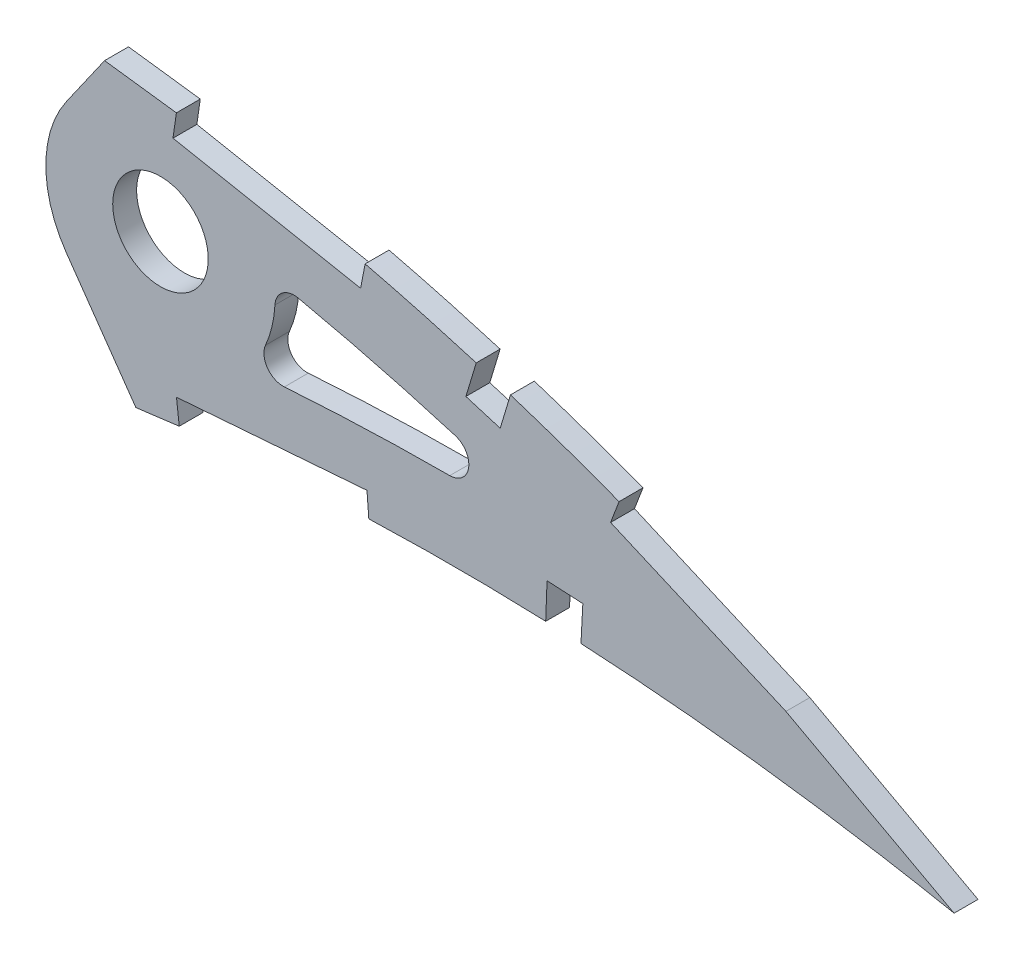
from build123d import *

# Parameters (mm, degrees)
BOSS_EXTRUDE1_DEPTH = 3.175
SKETCH3_R           = 6.35
CUT_EXTRUDE2_DEPTH  = 7.62
CUT_EXTRUDE3_DEPTH  = 4.1750001
CUT_EXTRUDE4_DEPTH  = 4.1750001
FILLET1_R           = 2.54


with BuildPart() as part:
    # Sketch1 → Boss-Extrude1 (new body)
    with BuildSketch(Plane.XY):
        with BuildLine():
            Line((383.459719795, -0.598570683), (387.151098381, -1.385981683))
            Line((387.151098381, -1.385981683), (383.938576586, 0.598570683))
            add(Edge.make_bspline(
                [(383.938576586, 0.598570683), (383.909164402, 0.616740215), (383.791629853, 0.689347806), (383.526803342, 0.851788775), (383.085812234, 1.122342517), (382.46846306, 1.499129399), (381.675235414, 1.981149322), (380.705730092, 2.565026812), (379.560552258, 3.248864764), (378.239979352, 4.02942936), (376.744146546, 4.903065392), (375.073623444, 5.866233811), (373.228555337, 6.913481558), (371.209656947, 8.040529653), (369.017620878, 9.242017712), (366.652862008, 10.5125194), (364.116227136, 11.845572217), (361.408689747, 13.235442203), (358.530743662, 14.674454529), (355.483745734, 16.156620323), (352.268711027, 17.674549225), (348.886737002, 19.220143157), (345.339766501, 20.787101279), (341.62878015, 22.365681942), (337.755892849, 23.949045726), (333.722753433, 25.528181676), (329.531749722, 27.095897536), (325.184498663, 28.642037582), (320.684250026, 30.159844956), (316.03318694, 31.639459621), (311.234635387, 33.072845765), (306.291383411, 34.45071), (301.207551835, 35.76598594), (295.986364862, 37.009095199), (290.632247735, 38.171716814), (285.149456354, 39.246851106), (279.542589067, 40.223764407), (273.827182957, 41.101695037), (268.095197614, 41.831984573), (262.375005403, 42.548231339), (256.663331957, 43.221079634), (250.881849899, 43.865424929), (245.036121341, 44.477639467), (239.131944816, 45.055808842), (233.175297421, 45.597437688), (227.172369204, 46.100937725), (221.12896887, 46.563455864), (215.051468851, 46.984279591), (208.945877574, 47.359709224), (202.818698224, 47.689463037), (196.676150699, 47.971241104), (190.524627328, 48.20310193), (184.370660154, 48.383645908), (178.220637202, 48.511143259), (172.081217377, 48.584792389), (165.95878665, 48.602580967), (159.860000816, 48.564190717), (153.791246295, 48.468303513), (147.759185686, 48.313606629), (141.770214134, 48.099811437), (135.830807778, 47.827010592), (129.947469668, 47.492919603), (124.126582163, 47.099667535), (118.374627308, 46.64560247), (112.697924861, 46.1306036), (107.102424066, 45.556817635), (101.594354639, 44.922683996), (96.179619551, 44.23000695), (90.864141437, 43.480144639), (85.653884398, 42.672688505), (80.554429795, 41.809970933), (75.571281385, 40.892874577), (70.709711341, 39.924088059), (65.975012599, 38.903864189), (61.372197101, 37.835263284), (56.906048373, 36.72014713), (52.581367423, 35.560557176), (48.402538226, 34.359275924), (44.373786491, 33.11902871), (40.499808771, 31.84117832), (36.783532955, 30.530569775), (33.229524089, 29.188133497), (29.840504666, 27.818005118), (26.620446377, 26.422055375), (23.571754691, 25.004539962), (20.697880073, 23.567072571), (18.000870717, 22.113680535), (15.483434196, 20.646592482), (13.147993867, 19.168533315), (10.995531238, 17.683252327), (9.029014018, 16.191681681), (7.249117676, 14.697590602), (5.656968684, 13.203254087), (4.254842735, 11.709701653), (3.042689485, 10.219563342), (2.022097407, 8.734019375), (1.193243635, 7.254475378), (0.55800286, 5.78200614), (0.115745172, 4.317439731), (-0.126343705, 2.862937809), (-0.186601112, 1.417334332), (-0.062107432, 0.471738862), (0, 0)],
                knots=[0, 0, 0, 0, 0.00025409, 0.001015374, 0.002283359, 0.004056577, 0.006330982, 0.009105274, 0.01237449, 0.016134024, 0.020379661, 0.025105976, 0.030306237, 0.035972206, 0.042099523, 0.048678064, 0.055701664, 0.063160184, 0.071045824, 0.079349827, 0.08806291, 0.097175757, 0.106678112, 0.116561573, 0.126814276, 0.1374283, 0.148393618, 0.15969976, 0.171338126, 0.183297699, 0.195569604, 0.208143556, 0.221011594, 0.234161831, 0.247587451, 0.261276823, 0.27522271, 0.289414144, 0.3037712, 0.317689227, 0.331784111, 0.346039677, 0.36044387, 0.374982721, 0.389640455, 0.404403317, 0.419256601, 0.43418675, 0.449177265, 0.464214782, 0.479284009, 0.49436974, 0.509457833, 0.524532346, 0.53957932, 0.554582984, 0.569529546, 0.584403417, 0.599190992, 0.613876838, 0.628447475, 0.642888675, 0.657186054, 0.671325546, 0.685294014, 0.699078148, 0.712665095, 0.726042645, 0.739197713, 0.752117587, 0.764792042, 0.777208152, 0.789355685, 0.80122396, 0.812803686, 0.824082909, 0.835054602, 0.845709571, 0.856037853, 0.866033835, 0.875688843, 0.884997719, 0.893953426, 0.902552897, 0.910789386, 0.918660734, 0.926166253, 0.933302626, 0.94007122, 0.94647478, 0.952517526, 0.958204819, 0.963546652, 0.9685566, 0.973249913, 0.977651041, 0.981787043, 0.985694226, 0.989415109, 0.993001157, 0.996508416, 1, 1, 1, 1], degree=3))
            add(Edge.make_bspline(
                [(0, 0), (0.098594067, -0.465429756), (0.296235321, -1.398428295), (0.833200827, -2.741559621), (1.543312041, -4.032697891), (2.441472641, -5.268413507), (3.521710628, -6.448368806), (4.781640288, -7.573790979), (6.220025893, -8.64407503), (7.834984953, -9.658733762), (9.624171422, -10.618844355), (11.585574313, -11.523809795), (13.717405168, -12.373347376), (16.017341357, -13.166321391), (18.482571114, -13.903939589), (21.110750633, -14.584404413), (23.898891402, -15.208666937), (26.844311765, -15.775133676), (29.943802121, -16.284380139), (33.194142548, -16.736121271), (36.59199678, -17.130639725), (40.134031288, -17.46710754), (43.816742631, -17.74624851), (47.636460203, -17.96824782), (51.589476278, -18.133809384), (55.672004278, -18.242303834), (59.880045838, -18.295422597), (64.209798061, -18.293963098), (68.657025429, -18.237535039), (73.217928944, -18.129255696), (77.888131918, -17.96843911), (82.663418096, -17.757031491), (87.53948011, -17.497160264), (92.511944666, -17.189706447), (97.576435823, -16.836032634), (102.728556211, -16.438975174), (107.9636256, -15.999524359), (113.277078315, -15.52024171), (118.664210326, -15.003526584), (124.120367239, -14.4510143), (129.640733027, -13.865303885), (135.220390799, -13.248293384), (140.854593983, -12.603274503), (146.538195749, -11.931414237), (152.266389991, -11.236548635), (158.033787934, -10.52000534), (163.835566864, -9.784544171), (169.666508639, -9.033628137), (175.521154495, -8.267171513), (181.394580274, -7.490635069), (187.28112183, -6.703379195), (193.175655329, -5.90945278), (199.072724256, -5.111323575), (204.966584816, -4.309237241), (210.852056119, -3.506517822), (216.72367834, -2.705368887), (222.575700149, -1.905863728), (228.402826975, -1.111976133), (234.199191111, -0.323609112), (239.959447702, 0.457639018), (245.678076832, 1.229436212), (251.34968319, 1.990808513), (256.968416226, 2.741274105), (262.528623029, 3.481114832), (267.941468501, 4.187874758), (273.192808754, 4.89918891), (278.300339848, 5.482308989), (283.344275668, 5.980022849), (288.329855672, 6.388079628), (293.25109327, 6.712349854), (298.102349784, 6.95515067), (302.877843519, 7.119871856), (307.571542288, 7.211400107), (312.17758361, 7.232058132), (316.689680406, 7.188433969), (321.101964205, 7.084044048), (325.408277014, 6.923573954), (329.602611012, 6.712437706), (333.679008651, 6.45639092), (337.631349997, 6.159210609), (341.4541277, 5.827834534), (345.141443703, 5.46711367), (348.687636023, 5.081169316), (352.087530269, 4.678088588), (355.335684636, 4.260525247), (358.42721331, 3.835341496), (361.357139876, 3.406846029), (364.120823945, 2.98050952), (366.713923524, 2.560399127), (369.132249836, 2.152090859), (371.372014685, 1.759399564), (373.429331453, 1.386160167), (375.301346074, 1.037081953), (376.984361404, 0.713898906), (378.476126466, 0.421937235), (379.773867448, 0.162485176), (380.875681878, -0.060801967), (381.779645661, -0.247042835), (382.484385883, -0.393180216), (382.98851051, -0.499447588), (383.291474212, -0.56268208), (383.426084821, -0.591395979), (383.459719795, -0.598570683)],
                knots=[0, 0, 0, 0, 0.003638255, 0.007293231, 0.011028136, 0.014901081, 0.018963272, 0.023258475, 0.027820626, 0.032679082, 0.03785316, 0.043361875, 0.049214679, 0.055422346, 0.061988786, 0.068918036, 0.076211157, 0.083868392, 0.091887411, 0.100265912, 0.108999867, 0.11808453, 0.127514843, 0.13728527, 0.147387918, 0.157816481, 0.168563473, 0.179619128, 0.190977373, 0.202626974, 0.214560478, 0.226767249, 0.239236417, 0.251959004, 0.264923895, 0.278119703, 0.291536035, 0.30516028, 0.318980685, 0.332985499, 0.347162791, 0.361498603, 0.375980747, 0.390597192, 0.405332594, 0.420174823, 0.435109533, 0.450124276, 0.465203068, 0.480333154, 0.495500583, 0.510689775, 0.525887335, 0.541078314, 0.556247233, 0.571381785, 0.586466041, 0.601484516, 0.616424329, 0.631269423, 0.646006524, 0.660620684, 0.675098187, 0.689422858, 0.703581825, 0.716907564, 0.730009274, 0.742952128, 0.755725558, 0.768319952, 0.780724338, 0.792926529, 0.804916041, 0.816679084, 0.828203524, 0.839474901, 0.850481359, 0.861207697, 0.871639326, 0.881763414, 0.891563605, 0.901027365, 0.910138977, 0.918883977, 0.927249278, 0.935221104, 0.942784739, 0.949928188, 0.956638465, 0.962904204, 0.968712288, 0.974054485, 0.978918432, 0.983297218, 0.987180246, 0.990560675, 0.993433358, 0.995790626, 0.997629588, 0.998945816, 0.999736593, 1, 1, 1, 1], degree=3))
        make_face()
    extrude(amount=BOSS_EXTRUDE1_DEPTH)

    # Sketch3 → Cut-Extrude2 (cut)
    with BuildSketch(Plane(origin=(0, 0, 0), x_dir=(-1, 0, 0), z_dir=(0, 0, -1))):
        with Locations((-272.41988512, 26.255421435)):
            Circle(SKETCH3_R)
    extrude(amount=-CUT_EXTRUDE2_DEPTH, mode=Mode.SUBTRACT)

    # Sketch4 → Cut-Extrude3 (cut, through all)
    with BuildSketch(Plane.XY.offset(3.175)):
        with BuildLine():
            ThreePointArc((258.636275142, 32.756936333), (259.238482127, 33.904487726), (259.936007965, 34.996726325))
            Line((259.936007965, 34.996726325), (264.993177896, 42.219113481))
            add(Edge.make_bspline(
                [(264.993177896, 42.219113481), (264.128267545, 42.326681207), (261.359885786, 42.667814769), (256.663331957, 43.221079634), (250.881849899, 43.865424929), (245.036121341, 44.477639467), (239.131944816, 45.055808842), (233.175297421, 45.597437688), (227.172369204, 46.100937725), (221.12896887, 46.563455864), (215.051468851, 46.984279591), (208.945877574, 47.359709224), (202.818698224, 47.689463037), (196.676150699, 47.971241104), (190.524627328, 48.20310193), (184.370660154, 48.383645908), (178.220637202, 48.511143259), (172.081217377, 48.584792389), (165.95878665, 48.602580967), (159.860000816, 48.564190717), (153.503835436, 48.463762379), (149.182034244, 48.349894835), (146.883754049, 48.276045968)],
                knots=[0.311283457, 0.311283457, 0.311283457, 0.311283457, 0.317689227, 0.331784111, 0.346039677, 0.36044387, 0.374982721, 0.389640455, 0.404403317, 0.419256601, 0.43418675, 0.449177265, 0.464214782, 0.479284009, 0.49436974, 0.509457833, 0.524532346, 0.53957932, 0.554582984, 0.569529546, 0.584403417, 0.601303588, 0.601303588, 0.601303588, 0.601303588], degree=3))
            add(Edge.make_bspline(
                [(146.883754049, 48.276045968), (145.173898454, 48.221104496), (141.483069263, 48.086622684), (135.830807778, 47.827010592), (129.947469668, 47.492919603), (124.126582163, 47.099667535), (118.374627308, 46.64560247), (112.697924861, 46.1306036), (107.102424066, 45.556817635), (101.594354639, 44.922683996), (96.179619551, 44.23000695), (90.864141437, 43.480144639), (85.653884398, 42.672688505), (80.554429795, 41.809970933), (75.571281385, 40.892874577), (70.709711341, 39.924088059), (65.975012599, 38.903864189), (61.372197101, 37.835263284), (56.906048373, 36.72014713), (52.581367423, 35.560557176), (48.402538226, 34.359275924), (44.373786491, 33.11902871), (40.499808771, 31.84117832), (36.783532955, 30.530569775), (33.229524089, 29.188133497), (29.840504666, 27.818005118), (26.620446377, 26.422055375), (23.571754691, 25.004539962), (20.697880073, 23.567072571), (18.000870717, 22.113680535), (15.483434196, 20.646592482), (13.147993867, 19.168533315), (10.995531238, 17.683252327), (9.029014018, 16.191681681), (7.249117676, 14.697590602), (5.656968684, 13.203254087), (4.254842735, 11.709701653), (3.042689485, 10.219563342), (2.022097407, 8.734019375), (1.193243635, 7.254475378), (0.55800286, 5.78200614), (0.115745172, 4.317439731), (-0.126343705, 2.862937809), (-0.186601112, 1.417334332), (-0.062107432, 0.471738862), (0, 0)],
                knots=[0.601303588, 0.601303588, 0.601303588, 0.601303588, 0.613876838, 0.628447475, 0.642888675, 0.657186054, 0.671325546, 0.685294014, 0.699078148, 0.712665095, 0.726042645, 0.739197713, 0.752117587, 0.764792042, 0.777208152, 0.789355685, 0.80122396, 0.812803686, 0.824082909, 0.835054602, 0.845709571, 0.856037853, 0.866033835, 0.875688843, 0.884997719, 0.893953426, 0.902552897, 0.910789386, 0.918660734, 0.926166253, 0.933302626, 0.94007122, 0.94647478, 0.952517526, 0.958204819, 0.963546652, 0.9685566, 0.973249913, 0.977651041, 0.981787043, 0.985694226, 0.989415109, 0.993001157, 0.996508416, 1, 1, 1, 1], degree=3))
            add(Edge.make_bspline(
                [(0, 0), (0.098594067, -0.465429756), (0.296235321, -1.398428295), (0.833200827, -2.741559621), (1.543312041, -4.032697891), (2.441472641, -5.268413507), (3.521710628, -6.448368806), (4.781640288, -7.573790979), (6.220025893, -8.64407503), (7.834984953, -9.658733762), (9.624171422, -10.618844355), (11.585574313, -11.523809795), (13.717405168, -12.373347376), (16.017341357, -13.166321391), (18.482571114, -13.903939589), (21.110750633, -14.584404413), (23.898891402, -15.208666937), (26.844311765, -15.775133676), (29.943802121, -16.284380139), (33.194142548, -16.736121271), (36.59199678, -17.130639725), (40.134031288, -17.46710754), (43.816742631, -17.74624851), (47.636460203, -17.96824782), (51.589476278, -18.133809384), (55.672004278, -18.242303834), (59.880045838, -18.295422597), (64.209798061, -18.293963098), (68.657025429, -18.237535039), (73.217928944, -18.129255696), (77.888131918, -17.96843911), (82.663418096, -17.757031491), (87.53948011, -17.497160264), (92.511944666, -17.189706447), (97.576435823, -16.836032634), (102.728556211, -16.438975174), (107.9636256, -15.999524359), (113.277078315, -15.52024171), (118.664210326, -15.003526584), (124.120367239, -14.4510143), (129.640733027, -13.865303885), (135.220390799, -13.248293384), (140.854593983, -12.603274503), (146.538195749, -11.931414237), (152.266389991, -11.236548635), (157.244201726, -10.618103774), (160.312006991, -10.230799494), (161.45711025, -10.085478827)],
                knots=[0, 0, 0, 0, 0.003638255, 0.007293231, 0.011028136, 0.014901081, 0.018963272, 0.023258475, 0.027820626, 0.032679082, 0.03785316, 0.043361875, 0.049214679, 0.055422346, 0.061988786, 0.068918036, 0.076211157, 0.083868392, 0.091887411, 0.100265912, 0.108999867, 0.11808453, 0.127514843, 0.13728527, 0.147387918, 0.157816481, 0.168563473, 0.179619128, 0.190977373, 0.202626974, 0.214560478, 0.226767249, 0.239236417, 0.251959004, 0.264923895, 0.278119703, 0.291536035, 0.30516028, 0.318980685, 0.332985499, 0.347162791, 0.361498603, 0.375980747, 0.390597192, 0.405332594, 0.420174823, 0.429015566, 0.429015566, 0.429015566, 0.429015566], degree=3))
            add(Edge.make_bspline(
                [(161.45711025, -10.085478827), (162.246435442, -9.985308592), (164.980400668, -9.63711103), (169.666508639, -9.033628137), (175.521154495, -8.267171513), (181.394580274, -7.490635069), (187.28112183, -6.703379195), (193.175655329, -5.90945278), (199.072724256, -5.111323575), (204.966584816, -4.309237241), (210.852056119, -3.506517822), (216.72367834, -2.705368887), (222.575700149, -1.905863728), (228.402826975, -1.111976133), (234.199191111, -0.323609112), (239.959447702, 0.457639018), (245.678076832, 1.229436212), (251.34968319, 1.990808513), (256.968416226, 2.741274105), (262.528623029, 3.481114832), (266.583838647, 4.010607851), (268.783690281, 4.304486241), (269.151142409, 4.353540657)],
                knots=[0.429015566, 0.429015566, 0.429015566, 0.429015566, 0.435109533, 0.450124276, 0.465203068, 0.480333154, 0.495500583, 0.510689775, 0.525887335, 0.541078314, 0.556247233, 0.571381785, 0.586466041, 0.601484516, 0.616424329, 0.631269423, 0.646006524, 0.660620684, 0.675098187, 0.689422858, 0.703581825, 0.706421091, 0.706421091, 0.706421091, 0.706421091], degree=3))
            Line((269.151142409, 4.353540657), (262.583654743, 13.732885077))
            Line((262.583654743, 13.732885077), (259.936007965, 17.514116545))
            ThreePointArc((259.936007965, 17.514116545), (257.234987727, 24.960627569), (258.636275142, 32.756936333))
        make_face()
        with BuildLine():
            add(Edge.make_bspline(
                [(327.549181489, 16.98603205), (326.824956948, 17.255063713), (321.470908621, 19.218235632), (311.379208006, 22.563584273), (298.702483107, 26.00149194), (290.712241282, 27.773311637), (287.505134836, 28.421718046)],
                knots=[0.144436945, 0.144436945, 0.144436945, 0.144436945, 0.150325897, 0.187907371, 0.225488845, 0.250466936, 0.250466936, 0.250466936, 0.250466936], degree=3))
            ThreePointArc((287.505134836, 28.421718046), (287.621148319, 27.341329886), (287.65988512, 26.255421435))
            ThreePointArc((287.65988512, 26.255421435), (286.68429662, 20.890333871), (283.882435702, 16.212138398))
            add(Edge.make_bspline(
                [(283.882435702, 16.212138398), (284.380055625, 16.254830388), (287.276976077, 16.496512621), (292.572797624, 16.8640824), (302.188464838, 17.315929241), (313.854957689, 17.470710505), (323.107860186, 17.20273134), (327.549181489, 16.98603205)],
                knots=[0.746492785, 0.746492785, 0.746492785, 0.746492785, 0.75019431, 0.768037574, 0.785880837, 0.821567364, 0.854595374, 0.854595374, 0.854595374, 0.854595374], degree=3))
        make_face()
    extrude(amount=-CUT_EXTRUDE3_DEPTH, mode=Mode.SUBTRACT)

    # Sketch5 → Cut-Extrude4 (cut, through all)
    with BuildSketch(Plane.XY.offset(3.175)):
        with BuildLine():
            add(Edge.make_bspline(
                [(299.624398141, 36.13644563), (298.424501349, 36.426858934), (295.444247173, 37.126813532), (290.632247735, 38.171716814), (285.149456354, 39.246851106), (279.770936215, 40.18397831), (276.216351623, 40.734415073), (274.534483108, 40.97601376)],
                knots=[0.225088548, 0.225088548, 0.225088548, 0.225088548, 0.234161831, 0.247587451, 0.261276823, 0.27522271, 0.287710696, 0.287710696, 0.287710696, 0.287710696], degree=3))
            Line((274.534483108, 40.97601376), (274.083031687, 37.833273457))
            Line((274.083031687, 37.833273457), (299.022613693, 33.018997879))
            Line((299.022613693, 33.018997879), (299.624398141, 36.13644563))
        make_face()
        with BuildLine():
            Line((274.545291907, 8.243392136), (274.917358333, 5.090268039))
            add(Edge.make_bspline(
                [(274.917358333, 5.090268039), (276.051562825, 5.224103371), (278.866167352, 5.53814241), (283.344275668, 5.980022849), (288.329855672, 6.388079628), (293.25109327, 6.712349854), (297.172305481, 6.908602829), (299.45218138, 6.997517141), (300.113766812, 7.021215382)],
                knots=[0.721262157, 0.721262157, 0.721262157, 0.721262157, 0.730009274, 0.742952128, 0.755725558, 0.768319952, 0.780724338, 0.785794655, 0.785794655, 0.785794655, 0.785794655], degree=3))
            Line((300.113766812, 7.021215382), (299.870827414, 10.18690732))
            Line((299.870827414, 10.18690732), (274.545291907, 8.243392136))
        make_face()
        with BuildLine():
            add(Edge.make_bspline(
                [(318.940828887, 30.710119476), (317.985349351, 31.016233704), (316.470853017, 31.492443021), (314.952360948, 31.955704373), (314.392994499, 32.124427397)],
                knots=[0.175923769, 0.175923769, 0.175923769, 0.175923769, 0.183297699, 0.187591729, 0.187591729, 0.187591729, 0.187591729], degree=3))
            Line((314.392994499, 32.124427397), (313.017673371, 27.564833331))
            Line((313.017673371, 27.564833331), (317.577267437, 26.189512203))
            Line((317.577267437, 26.189512203), (318.940828887, 30.710119476))
        make_face()
        with BuildLine():
            Line((323.807185741, 11.746480623), (323.625046444, 6.987464809))
            add(Edge.make_bspline(
                [(323.625046444, 6.987464809), (324.231568894, 6.964251695), (325.795034786, 6.900013286), (327.358005414, 6.824525333), (328.314492602, 6.774166864)],
                knots=[0.845832607, 0.845832607, 0.845832607, 0.845832607, 0.850481359, 0.857817238, 0.857817238, 0.857817238, 0.857817238], degree=3))
            Line((328.314492602, 6.774166864), (328.563098706, 11.496084697))
            Line((328.563098706, 11.496084697), (323.807185741, 11.746480623))
        make_face()
        with BuildLine():
            add(Edge.make_bspline(
                [(356.947809213, 15.442648045), (356.476147426, 15.671834195), (354.93622837, 16.415122177), (352.268711027, 17.674549225), (348.886737002, 19.220143157), (345.339766501, 20.787101279), (341.62878015, 22.365681942), (337.755892849, 23.949045726), (334.985526139, 25.033755481), (333.509547657, 25.597744153), (333.382575061, 25.646158956)],
                knots=[0.075495727, 0.075495727, 0.075495727, 0.075495727, 0.079349827, 0.08806291, 0.097175757, 0.106678112, 0.116561573, 0.126814276, 0.1374283, 0.13842703, 0.13842703, 0.13842703, 0.13842703], degree=3))
            Line((333.382575061, 25.646158956), (332.25138626, 22.679504798))
            Line((332.25138626, 22.679504798), (355.560182174, 12.586931637))
            Line((355.560182174, 12.586931637), (356.947809213, 15.442648045))
        make_face()
        with BuildLine():
            add(Edge.make_bspline(
                [(379.538106568, 3.260948486), (379.124721487, 3.506470471), (378.213445898, 4.044926133), (376.744146546, 4.903065392), (375.073623444, 5.866233811), (373.228555337, 6.913481558), (371.209656947, 8.040529653), (369.017620878, 9.242017712), (366.652862008, 10.5125194), (364.116227136, 11.845572217), (361.408689747, 13.235442203), (358.999781827, 14.439929044), (357.492384938, 15.178032133), (356.947809213, 15.442648045)],
                knots=[0.012600324, 0.012600324, 0.012600324, 0.012600324, 0.016134024, 0.020379661, 0.025105976, 0.030306237, 0.035972206, 0.042099523, 0.048678064, 0.055701664, 0.063160184, 0.071045824, 0.075495727, 0.075495727, 0.075495727, 0.075495727], degree=3))
            Line((356.947809213, 15.442648045), (355.560182174, 12.586931637))
            Line((355.560182174, 12.586931637), (377.916781847, 0.531125937))
            Line((377.916781847, 0.531125937), (379.538106568, 3.260948486))
        make_face()
        with BuildLine():
            add(Edge.make_bspline(
                [(383.938576586, 0.598570683), (383.909164402, 0.616740215), (383.791629853, 0.689347806), (383.526803342, 0.851788775), (383.085812234, 1.122342517), (382.46846306, 1.499129399), (381.675235414, 1.981149322), (380.705730092, 2.565026812), (379.973354152, 3.002361912), (379.564525487, 3.245257485), (379.538106568, 3.260948486)],
                knots=[0, 0, 0, 0, 0.00025409, 0.001015374, 0.002283359, 0.004056577, 0.006330982, 0.009105274, 0.01237449, 0.012600324, 0.012600324, 0.012600324, 0.012600324], degree=3))
            Line((379.538106568, 3.260948486), (377.916781847, 0.531125937))
            add(Edge.make_bspline(
                [(377.916781847, 0.531125937), (378.124660337, 0.490345398), (378.765544528, 0.364075063), (379.773867448, 0.162485176), (380.875681878, -0.060801967), (381.779645661, -0.247042835), (382.484385883, -0.393180216), (382.98851051, -0.499447588), (383.291474212, -0.56268208), (383.426084821, -0.591395979), (383.459719795, -0.598570683)],
                knots=[0.985557748, 0.985557748, 0.985557748, 0.985557748, 0.987180246, 0.990560675, 0.993433358, 0.995790626, 0.997629588, 0.998945816, 0.999736593, 1, 1, 1, 1], degree=3))
            Line((383.459719795, -0.598570683), (387.151098381, -1.385981683))
            Line((387.151098381, -1.385981683), (383.938576586, 0.598570683))
        make_face()
    extrude(amount=-CUT_EXTRUDE4_DEPTH, mode=Mode.SUBTRACT)

    # Fillet1
    fillet1_edges = [part.edges().sort_by_distance(p)[0] for p in [
        (327.549181489, 16.98603205, 1.5875),
        (287.505134836, 28.421718046, 1.5875),
        (283.882435702, 16.212138398, 1.5875),
    ]]
    fillet(fillet1_edges, radius=FILLET1_R)


solid = part.part
